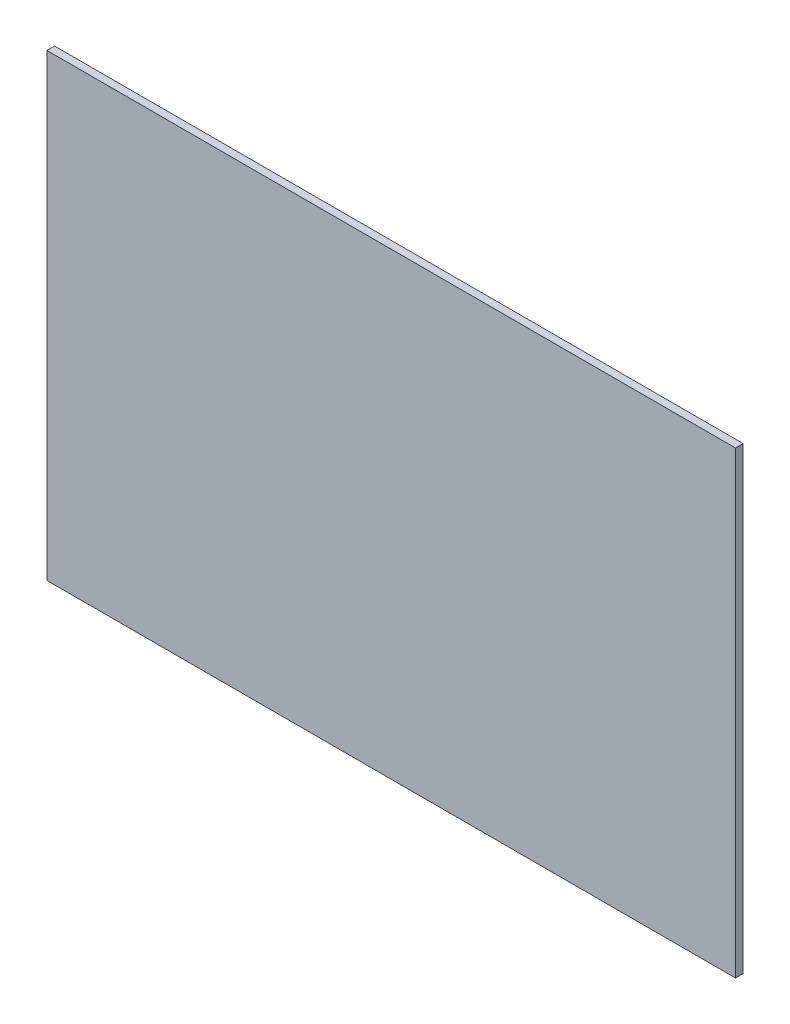
from build123d import *

# Parameters (mm, degrees)
ESQUISSE1_W        = 270
ESQUISSE1_H        = 180
BOSS_EXTRU_1_DEPTH = 3


with BuildPart() as part:
    # Esquisse1 → Boss.-Extru.1 (new body)
    with BuildSketch(Plane.XY):
        with Locations((69.349919944, -22.325761421)):
            Rectangle(ESQUISSE1_W, ESQUISSE1_H)
    extrude(amount=BOSS_EXTRU_1_DEPTH)


solid = part.part
